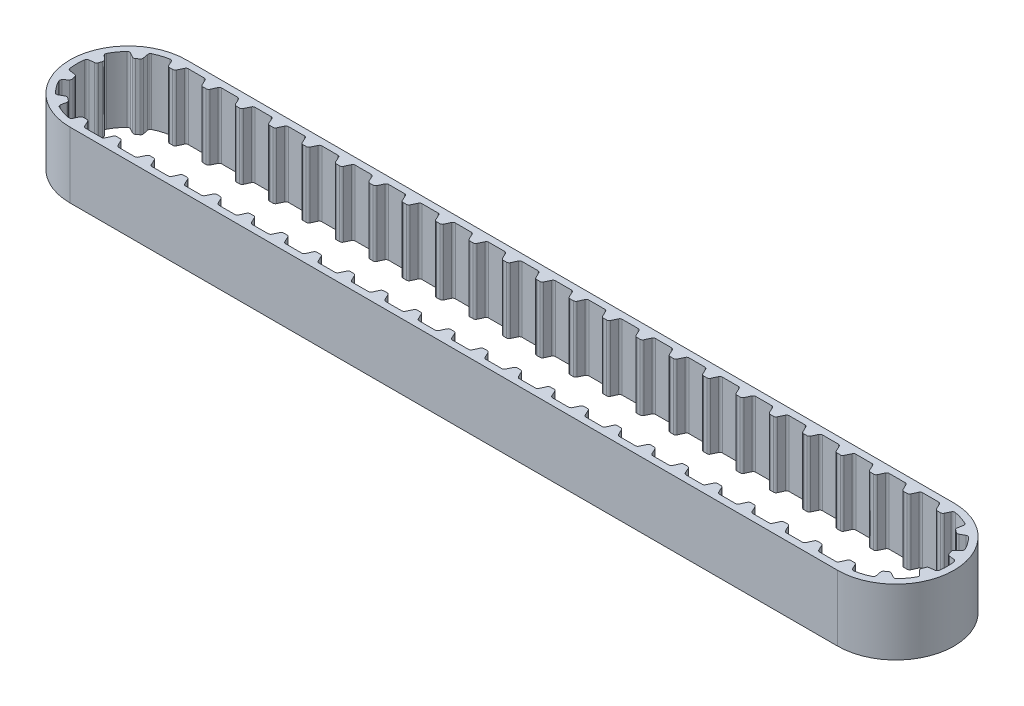
from build123d import *

# Parameters (mm, degrees)
BOSS_EXTRUDE1_DEPTH   = 10
BOSS_EXTRUDE2_DEPTH   = 10
CIRPATTERN1_COUNT     = 6
CIRPATTERN1_ANGLE     = 180.0000000000004
LPATTERN3_COUNT       = 23
LPATTERN3_PITCH       = 5.08
MIRROR1_COPY_1_DEPTH  = 10
MIRROR1_COPY_2_DEPTH  = 10
MIRROR1_COPY_3_DEPTH  = 10
MIRROR1_COPY_4_DEPTH  = 10
MIRROR1_COPY_5_DEPTH  = 10
MIRROR2_COPY_1_DEPTH  = 10
MIRROR2_COPY_2_DEPTH  = 10
MIRROR2_COPY_3_DEPTH  = 10
MIRROR2_COPY_4_DEPTH  = 10
MIRROR2_COPY_5_DEPTH  = 10
MIRROR2_COPY_6_DEPTH  = 10
MIRROR2_COPY_7_DEPTH  = 10
MIRROR2_COPY_8_DEPTH  = 10
MIRROR2_COPY_9_DEPTH  = 10
MIRROR2_COPY_10_DEPTH = 10
MIRROR2_COPY_11_DEPTH = 10
MIRROR2_COPY_12_DEPTH = 10
MIRROR2_COPY_13_DEPTH = 10
MIRROR2_COPY_14_DEPTH = 10
MIRROR2_COPY_15_DEPTH = 10
MIRROR2_COPY_16_DEPTH = 10
MIRROR2_COPY_17_DEPTH = 10
MIRROR2_COPY_18_DEPTH = 10
MIRROR2_COPY_19_DEPTH = 10
MIRROR2_COPY_20_DEPTH = 10
MIRROR2_COPY_21_DEPTH = 10
MIRROR2_COPY_22_DEPTH = 10
FILLET1_R             = 0.38


with BuildPart() as part:
    # Sketch1 → Boss-Extrude1 (new body)
    with BuildSketch(Plane(origin=(0, 0, 0), x_dir=(1, 0, 0), z_dir=(0, 1, 0))):
        with BuildLine():
            Line((0, 8.86), (116.84, 8.860000000000001))
            ThreePointArc((116.84, 8.860000000000001), (125.7, 0), (116.84, -8.860000000000001))
            Line((116.84, -8.860000000000001), (0, -8.86))
            ThreePointArc((0, -8.86), (-8.86, 1.09e-15), (0, 8.86))
        make_face()
        with BuildLine():
            Line((0, 7.829999999999998), (116.84, 7.83))
            ThreePointArc((116.84, 7.83), (124.67, 0), (116.84, -7.83))
            Line((116.84, -7.83), (0, -7.829999999999998))
            ThreePointArc((0, -7.829999999999998), (-7.829999999999998, 9.6e-16), (0, 7.829999999999998))
        make_face(mode=Mode.SUBTRACT)
    extrude(amount=BOSS_EXTRUDE1_DEPTH)

    # Sketch2 → Boss-Extrude2 (add)
    with BuildSketch(Plane(origin=(0, 10, 0), x_dir=(1, 0, 0), z_dir=(0, 1, 0))):
        with BuildLine():
            Line((-1.168761708860144, 8), (-0.4887772043281938, 6.541768524191946))
            ThreePointArc((-0.4887772043281938, 6.541768524191946), (-0.00621124619988731, 6.56), (0.4763883711050418, 6.542682378004853))
            Line((0.4763883711050418, 6.542682378004853), (1.1559467386055982, 8))
            Line((1.1559467386055982, 8), (-1.168761708860144, 8))
        make_face()
    boss_extrude2 = extrude(amount=-BOSS_EXTRUDE2_DEPTH)

    # CirPattern1: Boss-Extrude2 ×6 about axis
    cirpattern1_axis = Axis((4e-17, 0, 2.3e-16), (0, 1, 0))
    for i in range(1, CIRPATTERN1_COUNT):
        add(boss_extrude2.rotate(cirpattern1_axis, i * CIRPATTERN1_ANGLE / (CIRPATTERN1_COUNT - 1)))

    # LPattern3: Boss-Extrude2 ×23
    with Locations(*[(i * LPATTERN3_PITCH, 0, 0) for i in range(1, LPATTERN3_COUNT)]):
        add(boss_extrude2)

    # Mirror1: Boss-Extrude2 across plane
    add(boss_extrude2.mirror(Plane(origin=(58.42, 0, 0), x_dir=(0, 0, 1), z_dir=(1, 0, 0))))

    # Mirror1 copy 1 sketch → Mirror1 copy 1 (add)
    with BuildSketch(Plane(origin=(116.84, 10, 7e-17), x_dir=(-0.8090169943749467, 0, -0.5877852522924741), z_dir=(0, 1, 0))):
        with BuildLine():
            Line((-1.168761708860144, -8), (-0.4887772043281938, -6.541768524191946))
            ThreePointArc((-0.4887772043281938, -6.541768524191946), (-0.00621124619988731, -6.56), (0.4763883711050418, -6.542682378004853))
            Line((0.4763883711050418, -6.542682378004853), (1.1559467386055982, -8))
            Line((1.1559467386055982, -8), (-1.168761708860144, -8))
        make_face()
    extrude(amount=-MIRROR1_COPY_1_DEPTH)

    # Mirror1 copy 2 sketch → Mirror1 copy 2 (add)
    with BuildSketch(Plane(origin=(116.84, 10, 2e-16), x_dir=(-0.30901699437494495, 0, -0.9510565162951544), z_dir=(0, 1, 0))):
        with BuildLine():
            Line((-1.168761708860144, -8), (-0.4887772043281938, -6.541768524191946))
            ThreePointArc((-0.4887772043281938, -6.541768524191946), (-0.00621124619988731, -6.56), (0.4763883711050418, -6.542682378004853))
            Line((0.4763883711050418, -6.542682378004853), (1.1559467386055982, -8))
            Line((1.1559467386055982, -8), (-1.168761708860144, -8))
        make_face()
    extrude(amount=-MIRROR1_COPY_2_DEPTH)

    # Mirror1 copy 3 sketch → Mirror1 copy 3 (add)
    with BuildSketch(Plane(origin=(116.84, 10, 3.4e-16), x_dir=(0.30901699437495117, 0, -0.9510565162951523), z_dir=(0, 1, 0))):
        with BuildLine():
            Line((-1.168761708860144, -8), (-0.4887772043281938, -6.541768524191946))
            ThreePointArc((-0.4887772043281938, -6.541768524191946), (-0.00621124619988731, -6.56), (0.4763883711050418, -6.542682378004853))
            Line((0.4763883711050418, -6.542682378004853), (1.1559467386055982, -8))
            Line((1.1559467386055982, -8), (-1.168761708860144, -8))
        make_face()
    extrude(amount=-MIRROR1_COPY_3_DEPTH)

    # Mirror1 copy 4 sketch → Mirror1 copy 4 (add)
    with BuildSketch(Plane(origin=(116.84, 10, 4.4e-16), x_dir=(0.8090169943749504, 0, -0.5877852522924689), z_dir=(0, 1, 0))):
        with BuildLine():
            Line((-1.168761708860144, -8), (-0.4887772043281938, -6.541768524191946))
            ThreePointArc((-0.4887772043281938, -6.541768524191946), (-0.00621124619988731, -6.56), (0.4763883711050418, -6.542682378004853))
            Line((0.4763883711050418, -6.542682378004853), (1.1559467386055982, -8))
            Line((1.1559467386055982, -8), (-1.168761708860144, -8))
        make_face()
    extrude(amount=-MIRROR1_COPY_4_DEPTH)

    # Mirror1 copy 5 sketch → Mirror1 copy 5 (add)
    with BuildSketch(Plane(origin=(116.84, 10, 4.6e-16), x_dir=(1, 0, 6.98e-15), z_dir=(0, 1, 0))):
        with BuildLine():
            Line((-1.168761708860144, -8), (-0.4887772043281938, -6.541768524191946))
            ThreePointArc((-0.4887772043281938, -6.541768524191946), (-0.00621124619988731, -6.56), (0.4763883711050418, -6.542682378004853))
            Line((0.4763883711050418, -6.542682378004853), (1.1559467386055982, -8))
            Line((1.1559467386055982, -8), (-1.168761708860144, -8))
        make_face()
    extrude(amount=-MIRROR1_COPY_5_DEPTH)

    # Mirror2: Boss-Extrude2 across plane
    add(boss_extrude2.mirror(Plane.XY))

    # Mirror2 copy 1 sketch → Mirror2 copy 1 (add)
    with BuildSketch(Plane(origin=(5.08, 10, -6e-17), x_dir=(1, 0, 0), z_dir=(0, 1, 0))):
        with BuildLine():
            Line((-1.168761708860144, -8), (-0.4887772043281938, -6.541768524191946))
            ThreePointArc((-0.4887772043281938, -6.541768524191946), (-0.00621124619988731, -6.56), (0.4763883711050418, -6.542682378004853))
            Line((0.4763883711050418, -6.542682378004853), (1.1559467386055982, -8))
            Line((1.1559467386055982, -8), (-1.168761708860144, -8))
        make_face()
    extrude(amount=-MIRROR2_COPY_1_DEPTH)

    # Mirror2 copy 2 sketch → Mirror2 copy 2 (add)
    with BuildSketch(Plane(origin=(10.16, 10, -1.3e-16), x_dir=(1, 0, 0), z_dir=(0, 1, 0))):
        with BuildLine():
            Line((-1.168761708860144, -8), (-0.4887772043281938, -6.541768524191946))
            ThreePointArc((-0.4887772043281938, -6.541768524191946), (-0.00621124619988731, -6.56), (0.4763883711050418, -6.542682378004853))
            Line((0.4763883711050418, -6.542682378004853), (1.1559467386055982, -8))
            Line((1.1559467386055982, -8), (-1.168761708860144, -8))
        make_face()
    extrude(amount=-MIRROR2_COPY_2_DEPTH)

    # Mirror2 copy 3 sketch → Mirror2 copy 3 (add)
    with BuildSketch(Plane(origin=(15.24, 10, -1.9e-16), x_dir=(1, 0, 0), z_dir=(0, 1, 0))):
        with BuildLine():
            Line((-1.168761708860144, -8), (-0.4887772043281938, -6.541768524191946))
            ThreePointArc((-0.4887772043281938, -6.541768524191946), (-0.00621124619988731, -6.56), (0.4763883711050418, -6.542682378004853))
            Line((0.4763883711050418, -6.542682378004853), (1.1559467386055982, -8))
            Line((1.1559467386055982, -8), (-1.168761708860144, -8))
        make_face()
    extrude(amount=-MIRROR2_COPY_3_DEPTH)

    # Mirror2 copy 4 sketch → Mirror2 copy 4 (add)
    with BuildSketch(Plane(origin=(20.32, 10, -2.6e-16), x_dir=(1, 0, 0), z_dir=(0, 1, 0))):
        with BuildLine():
            Line((-1.168761708860144, -8), (-0.4887772043281938, -6.541768524191946))
            ThreePointArc((-0.4887772043281938, -6.541768524191946), (-0.00621124619988731, -6.56), (0.4763883711050418, -6.542682378004853))
            Line((0.4763883711050418, -6.542682378004853), (1.1559467386055982, -8))
            Line((1.1559467386055982, -8), (-1.168761708860144, -8))
        make_face()
    extrude(amount=-MIRROR2_COPY_4_DEPTH)

    # Mirror2 copy 5 sketch → Mirror2 copy 5 (add)
    with BuildSketch(Plane(origin=(25.4, 10, -3.2e-16), x_dir=(1, 0, 0), z_dir=(0, 1, 0))):
        with BuildLine():
            Line((-1.168761708860144, -8), (-0.4887772043281938, -6.541768524191946))
            ThreePointArc((-0.4887772043281938, -6.541768524191946), (-0.00621124619988731, -6.56), (0.4763883711050418, -6.542682378004853))
            Line((0.4763883711050418, -6.542682378004853), (1.1559467386055982, -8))
            Line((1.1559467386055982, -8), (-1.168761708860144, -8))
        make_face()
    extrude(amount=-MIRROR2_COPY_5_DEPTH)

    # Mirror2 copy 6 sketch → Mirror2 copy 6 (add)
    with BuildSketch(Plane(origin=(30.48, 10, -3.9e-16), x_dir=(1, 0, 0), z_dir=(0, 1, 0))):
        with BuildLine():
            Line((-1.168761708860144, -8), (-0.4887772043281938, -6.541768524191946))
            ThreePointArc((-0.4887772043281938, -6.541768524191946), (-0.00621124619988731, -6.56), (0.4763883711050418, -6.542682378004853))
            Line((0.4763883711050418, -6.542682378004853), (1.1559467386055982, -8))
            Line((1.1559467386055982, -8), (-1.168761708860144, -8))
        make_face()
    extrude(amount=-MIRROR2_COPY_6_DEPTH)

    # Mirror2 copy 7 sketch → Mirror2 copy 7 (add)
    with BuildSketch(Plane(origin=(35.56, 10, -4.5e-16), x_dir=(1, 0, 0), z_dir=(0, 1, 0))):
        with BuildLine():
            Line((-1.168761708860144, -8), (-0.4887772043281938, -6.541768524191946))
            ThreePointArc((-0.4887772043281938, -6.541768524191946), (-0.00621124619988731, -6.56), (0.4763883711050418, -6.542682378004853))
            Line((0.4763883711050418, -6.542682378004853), (1.1559467386055982, -8))
            Line((1.1559467386055982, -8), (-1.168761708860144, -8))
        make_face()
    extrude(amount=-MIRROR2_COPY_7_DEPTH)

    # Mirror2 copy 8 sketch → Mirror2 copy 8 (add)
    with BuildSketch(Plane(origin=(40.64, 10, -5.2e-16), x_dir=(1, 0, 0), z_dir=(0, 1, 0))):
        with BuildLine():
            Line((-1.168761708860144, -8), (-0.4887772043281938, -6.541768524191946))
            ThreePointArc((-0.4887772043281938, -6.541768524191946), (-0.00621124619988731, -6.56), (0.4763883711050418, -6.542682378004853))
            Line((0.4763883711050418, -6.542682378004853), (1.1559467386055982, -8))
            Line((1.1559467386055982, -8), (-1.168761708860144, -8))
        make_face()
    extrude(amount=-MIRROR2_COPY_8_DEPTH)

    # Mirror2 copy 9 sketch → Mirror2 copy 9 (add)
    with BuildSketch(Plane(origin=(45.72, 10, -5.8e-16), x_dir=(1, 0, 0), z_dir=(0, 1, 0))):
        with BuildLine():
            Line((-1.168761708860144, -8), (-0.4887772043281938, -6.541768524191946))
            ThreePointArc((-0.4887772043281938, -6.541768524191946), (-0.00621124619988731, -6.56), (0.4763883711050418, -6.542682378004853))
            Line((0.4763883711050418, -6.542682378004853), (1.1559467386055982, -8))
            Line((1.1559467386055982, -8), (-1.168761708860144, -8))
        make_face()
    extrude(amount=-MIRROR2_COPY_9_DEPTH)

    # Mirror2 copy 10 sketch → Mirror2 copy 10 (add)
    with BuildSketch(Plane(origin=(50.8, 10, -6.5e-16), x_dir=(1, 0, 0), z_dir=(0, 1, 0))):
        with BuildLine():
            Line((-1.168761708860144, -8), (-0.4887772043281938, -6.541768524191946))
            ThreePointArc((-0.4887772043281938, -6.541768524191946), (-0.00621124619988731, -6.56), (0.4763883711050418, -6.542682378004853))
            Line((0.4763883711050418, -6.542682378004853), (1.1559467386055982, -8))
            Line((1.1559467386055982, -8), (-1.168761708860144, -8))
        make_face()
    extrude(amount=-MIRROR2_COPY_10_DEPTH)

    # Mirror2 copy 11 sketch → Mirror2 copy 11 (add)
    with BuildSketch(Plane(origin=(55.88, 10, -7.1e-16), x_dir=(1, 0, 0), z_dir=(0, 1, 0))):
        with BuildLine():
            Line((-1.168761708860144, -8), (-0.4887772043281938, -6.541768524191946))
            ThreePointArc((-0.4887772043281938, -6.541768524191946), (-0.00621124619988731, -6.56), (0.4763883711050418, -6.542682378004853))
            Line((0.4763883711050418, -6.542682378004853), (1.1559467386055982, -8))
            Line((1.1559467386055982, -8), (-1.168761708860144, -8))
        make_face()
    extrude(amount=-MIRROR2_COPY_11_DEPTH)

    # Mirror2 copy 12 sketch → Mirror2 copy 12 (add)
    with BuildSketch(Plane(origin=(60.96, 10, -7.7e-16), x_dir=(1, 0, 0), z_dir=(0, 1, 0))):
        with BuildLine():
            Line((-1.168761708860144, -8), (-0.4887772043281938, -6.541768524191946))
            ThreePointArc((-0.4887772043281938, -6.541768524191946), (-0.00621124619988731, -6.56), (0.4763883711050418, -6.542682378004853))
            Line((0.4763883711050418, -6.542682378004853), (1.1559467386055982, -8))
            Line((1.1559467386055982, -8), (-1.168761708860144, -8))
        make_face()
    extrude(amount=-MIRROR2_COPY_12_DEPTH)

    # Mirror2 copy 13 sketch → Mirror2 copy 13 (add)
    with BuildSketch(Plane(origin=(66.04, 10, -8.4e-16), x_dir=(1, 0, 0), z_dir=(0, 1, 0))):
        with BuildLine():
            Line((-1.168761708860144, -8), (-0.4887772043281938, -6.541768524191946))
            ThreePointArc((-0.4887772043281938, -6.541768524191946), (-0.00621124619988731, -6.56), (0.4763883711050418, -6.542682378004853))
            Line((0.4763883711050418, -6.542682378004853), (1.1559467386055982, -8))
            Line((1.1559467386055982, -8), (-1.168761708860144, -8))
        make_face()
    extrude(amount=-MIRROR2_COPY_13_DEPTH)

    # Mirror2 copy 14 sketch → Mirror2 copy 14 (add)
    with BuildSketch(Plane(origin=(71.12, 10, -9e-16), x_dir=(1, 0, 0), z_dir=(0, 1, 0))):
        with BuildLine():
            Line((-1.168761708860144, -8), (-0.4887772043281938, -6.541768524191946))
            ThreePointArc((-0.4887772043281938, -6.541768524191946), (-0.00621124619988731, -6.56), (0.4763883711050418, -6.542682378004853))
            Line((0.4763883711050418, -6.542682378004853), (1.1559467386055982, -8))
            Line((1.1559467386055982, -8), (-1.168761708860144, -8))
        make_face()
    extrude(amount=-MIRROR2_COPY_14_DEPTH)

    # Mirror2 copy 15 sketch → Mirror2 copy 15 (add)
    with BuildSketch(Plane(origin=(76.2, 10, -9.7e-16), x_dir=(1, 0, 0), z_dir=(0, 1, 0))):
        with BuildLine():
            Line((-1.168761708860144, -8), (-0.4887772043281938, -6.541768524191946))
            ThreePointArc((-0.4887772043281938, -6.541768524191946), (-0.00621124619988731, -6.56), (0.4763883711050418, -6.542682378004853))
            Line((0.4763883711050418, -6.542682378004853), (1.1559467386055982, -8))
            Line((1.1559467386055982, -8), (-1.168761708860144, -8))
        make_face()
    extrude(amount=-MIRROR2_COPY_15_DEPTH)

    # Mirror2 copy 16 sketch → Mirror2 copy 16 (add)
    with BuildSketch(Plane(origin=(81.28, 10, -1.03e-15), x_dir=(1, 0, 0), z_dir=(0, 1, 0))):
        with BuildLine():
            Line((-1.168761708860144, -8), (-0.4887772043281938, -6.541768524191946))
            ThreePointArc((-0.4887772043281938, -6.541768524191946), (-0.00621124619988731, -6.56), (0.4763883711050418, -6.542682378004853))
            Line((0.4763883711050418, -6.542682378004853), (1.1559467386055982, -8))
            Line((1.1559467386055982, -8), (-1.168761708860144, -8))
        make_face()
    extrude(amount=-MIRROR2_COPY_16_DEPTH)

    # Mirror2 copy 17 sketch → Mirror2 copy 17 (add)
    with BuildSketch(Plane(origin=(86.36, 10, -1.1e-15), x_dir=(1, 0, 0), z_dir=(0, 1, 0))):
        with BuildLine():
            Line((-1.168761708860144, -8), (-0.4887772043281938, -6.541768524191946))
            ThreePointArc((-0.4887772043281938, -6.541768524191946), (-0.00621124619988731, -6.56), (0.4763883711050418, -6.542682378004853))
            Line((0.4763883711050418, -6.542682378004853), (1.1559467386055982, -8))
            Line((1.1559467386055982, -8), (-1.168761708860144, -8))
        make_face()
    extrude(amount=-MIRROR2_COPY_17_DEPTH)

    # Mirror2 copy 18 sketch → Mirror2 copy 18 (add)
    with BuildSketch(Plane(origin=(91.44, 10, -1.16e-15), x_dir=(1, 0, 0), z_dir=(0, 1, 0))):
        with BuildLine():
            Line((-1.168761708860144, -8), (-0.4887772043281938, -6.541768524191946))
            ThreePointArc((-0.4887772043281938, -6.541768524191946), (-0.00621124619988731, -6.56), (0.4763883711050418, -6.542682378004853))
            Line((0.4763883711050418, -6.542682378004853), (1.1559467386055982, -8))
            Line((1.1559467386055982, -8), (-1.168761708860144, -8))
        make_face()
    extrude(amount=-MIRROR2_COPY_18_DEPTH)

    # Mirror2 copy 19 sketch → Mirror2 copy 19 (add)
    with BuildSketch(Plane(origin=(96.52, 10, -1.23e-15), x_dir=(1, 0, 0), z_dir=(0, 1, 0))):
        with BuildLine():
            Line((-1.168761708860144, -8), (-0.4887772043281938, -6.541768524191946))
            ThreePointArc((-0.4887772043281938, -6.541768524191946), (-0.00621124619988731, -6.56), (0.4763883711050418, -6.542682378004853))
            Line((0.4763883711050418, -6.542682378004853), (1.1559467386055982, -8))
            Line((1.1559467386055982, -8), (-1.168761708860144, -8))
        make_face()
    extrude(amount=-MIRROR2_COPY_19_DEPTH)

    # Mirror2 copy 20 sketch → Mirror2 copy 20 (add)
    with BuildSketch(Plane(origin=(101.6, 10, -1.29e-15), x_dir=(1, 0, 0), z_dir=(0, 1, 0))):
        with BuildLine():
            Line((-1.168761708860144, -8), (-0.4887772043281938, -6.541768524191946))
            ThreePointArc((-0.4887772043281938, -6.541768524191946), (-0.00621124619988731, -6.56), (0.4763883711050418, -6.542682378004853))
            Line((0.4763883711050418, -6.542682378004853), (1.1559467386055982, -8))
            Line((1.1559467386055982, -8), (-1.168761708860144, -8))
        make_face()
    extrude(amount=-MIRROR2_COPY_20_DEPTH)

    # Mirror2 copy 21 sketch → Mirror2 copy 21 (add)
    with BuildSketch(Plane(origin=(106.68, 10, -1.35e-15), x_dir=(1, 0, 0), z_dir=(0, 1, 0))):
        with BuildLine():
            Line((-1.168761708860144, -8), (-0.4887772043281938, -6.541768524191946))
            ThreePointArc((-0.4887772043281938, -6.541768524191946), (-0.00621124619988731, -6.56), (0.4763883711050418, -6.542682378004853))
            Line((0.4763883711050418, -6.542682378004853), (1.1559467386055982, -8))
            Line((1.1559467386055982, -8), (-1.168761708860144, -8))
        make_face()
    extrude(amount=-MIRROR2_COPY_21_DEPTH)

    # Mirror2 copy 22 sketch → Mirror2 copy 22 (add)
    with BuildSketch(Plane(origin=(111.76, 10, -1.42e-15), x_dir=(1, 0, 0), z_dir=(0, 1, 0))):
        with BuildLine():
            Line((-1.168761708860144, -8), (-0.4887772043281938, -6.541768524191946))
            ThreePointArc((-0.4887772043281938, -6.541768524191946), (-0.00621124619988731, -6.56), (0.4763883711050418, -6.542682378004853))
            Line((0.4763883711050418, -6.542682378004853), (1.1559467386055982, -8))
            Line((1.1559467386055982, -8), (-1.168761708860144, -8))
        make_face()
    extrude(amount=-MIRROR2_COPY_22_DEPTH)

    # Fillet1
    fillet1_edges = [part.edges().sort_by_distance(p)[0] for p in [
        (-6.070551120426782, 5, 2.4863723924353116),
        (41.716674436719245, 5, 7.829999999999999),
        (39.55051059302621, 5, 7.829999999999999),
        (40.151222795671806, 5, 6.541768524191945),
        (41.116388371105046, 5, 6.542682378004852),
        (-7.702908480901908, 5, 1.4050270228182267),
        (46.796674436719236, 5, 7.829999999999999),
        (44.6305105930262, 5, 7.829999999999999),
        (45.231222795671805, 5, 6.541768524191945),
        (46.196388371105044, 5, 6.542682378004852),
        (51.87667443671924, 5, 7.829999999999999),
        (49.7105105930262, 5, 7.829999999999999),
        (50.3112227956718, 5, 6.541768524191945),
        (51.27638837110504, 5, 6.542682378004852),
        (56.95667443671925, 5, 7.829999999999999),
        (54.790510593026205, 5, 7.829999999999999),
        (55.39122279567181, 5, 6.541768524191945),
        (56.35638837110504, 5, 6.542682378004852),
        (62.03667443671924, 5, 7.829999999999999),
        (59.870510593026204, 5, 7.829999999999999),
        (60.47122279567181, 5, 6.541768524191945),
        (61.43638837110504, 5, 6.542682378004852),
        (67.11667443671925, 5, 7.829999999999999),
        (64.95051059302622, 5, 7.829999999999999),
        (65.55122279567182, 5, 6.541768524191945),
        (66.51638837110505, 5, 6.542682378004852),
        (72.19667443671926, 5, 7.829999999999999),
        (70.03051059302621, 5, 7.829999999999999),
        (70.63122279567182, 5, 6.541768524191945),
        (71.59638837110505, 5, 6.542682378004852),
        (77.27667443671925, 5, 7.829999999999999),
        (75.1105105930262, 5, 7.829999999999999),
        (75.71122279567182, 5, 6.541768524191945),
        (76.67638837110505, 5, 6.542682378004852),
        (82.35667443671926, 5, 7.829999999999999),
        (80.1905105930262, 5, 7.829999999999999),
        (80.79122279567181, 5, 6.541768524191945),
        (81.75638837110505, 5, 6.542682378004852),
        (-4.231098500371653, 5, 5.013127173704265),
        (-3.705878746643041, 5, 6.897489595148324),
        (87.43667443671924, 5, 7.829999999999999),
        (85.27051059302619, 5, 7.829999999999999),
        (-3.4497259976665084, 5, 5.579697941699279),
        (85.87122279567181, 5, 6.541768524191945),
        (86.83638837110504, 5, 6.542682378004852),
        (-5.405929704079593, 5, 5.664346743848748),
        (92.51667443671926, 5, 7.83),
        (90.3505105930262, 5, 7.83),
        (90.95122279567181, 5, 6.541768524191945),
        (91.91638837110504, 5, 6.542682378004852),
        (97.59667443671924, 5, 7.83),
        (95.43051059302618, 5, 7.83),
        (96.03122279567181, 5, 6.541768524191945),
        (96.99638837110504, 5, 6.542682378004852),
        (102.67667443671925, 5, 7.83),
        (100.5105105930262, 5, 7.83),
        (101.11122279567181, 5, 6.541768524191945),
        (102.07638837110504, 5, 6.542682378004852),
        (107.75667443671927, 5, 7.83),
        (105.59051059302621, 5, 7.83),
        (106.19122279567182, 5, 6.541768524191944),
        (107.15638837110505, 5, 6.5426823780048515),
        (112.83667443671925, 5, 7.83),
        (110.6705105930262, 5, 7.83),
        (111.27122279567182, 5, 6.541768524191944),
        (112.23638837110505, 5, 6.5426823780048515),
        (1.089489406973846, 5, 7.829999999999998),
        (0.4887772043282396, 5, 6.541768524191943),
        (6.156674436719248, 5, -7.829999999999998),
        (3.9905105930262055, 5, -7.829999999999998),
        (5.556388371105042, 5, -6.542682378004853),
        (4.591222795671806, 5, -6.541768524191946),
        (11.236674436719248, 5, -7.829999999999998),
        (9.070510593026206, 5, -7.829999999999998),
        (10.636388371105042, 5, -6.542682378004853),
        (9.671222795671806, 5, -6.541768524191946),
        (16.31667443671925, 5, -7.829999999999998),
        (14.150510593026205, 5, -7.829999999999998),
        (15.716388371105042, 5, -6.542682378004853),
        (14.751222795671806, 5, -6.541768524191946),
        (21.396674436719245, 5, -7.829999999999998),
        (19.230510593026203, 5, -7.829999999999998),
        (20.796388371105042, 5, -6.542682378004853),
        (19.831222795671806, 5, -6.541768524191946),
        (26.476674436719247, 5, -7.829999999999998),
        (24.3105105930262, 5, -7.829999999999998),
        (25.87638837110504, 5, -6.542682378004853),
        (24.911222795671804, 5, -6.541768524191946),
        (31.55667443671925, 5, -7.829999999999999),
        (29.390510593026203, 5, -7.829999999999999),
        (30.956388371105042, 5, -6.542682378004853),
        (29.991222795671806, 5, -6.541768524191946),
        (1.076674436719249, 5, -7.829999999999998),
        (36.636674436719254, 5, -7.829999999999999),
        (34.470510593026205, 5, -7.829999999999999),
        (36.03638837110505, 5, -6.542682378004852),
        (35.07122279567181, 5, -6.541768524191945),
        (-1.0561237767417748, 5, -7.758447175060267),
        (41.716674436719245, 5, -7.829999999999999),
        (39.5505105930262, 5, -7.829999999999999),
        (41.116388371105046, 5, -6.542682378004852),
        (40.151222795671806, 5, -6.541768524191945),
        (46.79667443671924, 5, -7.829999999999999),
        (44.6305105930262, 5, -7.829999999999999),
        (46.196388371105044, 5, -6.542682378004852),
        (45.231222795671805, 5, -6.541768524191945),
        (0.47638837110504184, 5, -6.542682378004853),
        (-0.4887772043281938, 5, -6.541768524191946),
        (51.87667443671924, 5, -7.829999999999999),
        (49.7105105930262, 5, -7.829999999999999),
        (51.27638837110504, 5, -6.542682378004852),
        (50.3112227956718, 5, -6.541768524191945),
        (56.95667443671925, 5, -7.829999999999999),
        (54.790510593026205, 5, -7.829999999999999),
        (56.35638837110504, 5, -6.542682378004852),
        (55.39122279567181, 5, -6.541768524191945),
        (62.036674436719245, 5, -7.829999999999999),
        (59.87051059302621, 5, -7.829999999999999),
        (61.43638837110504, 5, -6.542682378004852),
        (60.47122279567181, 5, -6.541768524191945),
        (67.11667443671926, 5, -7.829999999999999),
        (64.95051059302621, 5, -7.829999999999999),
        (66.51638837110505, 5, -6.542682378004852),
        (65.55122279567182, 5, -6.541768524191945),
        (72.19667443671926, 5, -7.829999999999999),
        (70.03051059302621, 5, -7.829999999999999),
        (71.59638837110505, 5, -6.542682378004852),
        (70.63122279567182, 5, -6.541768524191945),
        (77.27667443671925, 5, -7.829999999999999),
        (75.1105105930262, 5, -7.829999999999999),
        (76.67638837110505, 5, -6.542682378004852),
        (75.71122279567182, 5, -6.541768524191945),
        (82.35667443671926, 5, -7.829999999999999),
        (80.1905105930262, 5, -7.829999999999999),
        (81.75638837110505, 5, -6.542682378004852),
        (80.79122279567181, 5, -6.541768524191945),
        (-3.716589732335633, 5, -6.891724077580103),
        (87.43667443671926, 5, -7.829999999999999),
        (85.27051059302619, 5, -7.829999999999999),
        (-5.414722913738181, 5, -5.655941634019808),
        (86.83638837110504, 5, -6.542682378004852),
        (85.87122279567181, 5, -6.541768524191945),
        (92.51667443671926, 5, -7.83),
        (90.3505105930262, 5, -7.83),
        (91.91638837110504, 5, -6.542682378004852),
        (90.95122279567181, 5, -6.541768524191945),
        (97.59667443671924, 5, -7.83),
        (95.43051059302618, 5, -7.83),
        (96.99638837110504, 5, -6.542682378004852),
        (96.03122279567181, 5, -6.541768524191945),
        (-3.46028592407853, 5, -5.573155291502593),
        (-4.240584127195714, 5, -5.005105876977542),
        (102.67667443671925, 5, -7.83),
        (100.51051059302618, 5, -7.83),
        (102.07638837110504, 5, -6.542682378004852),
        (101.11122279567181, 5, -6.541768524191945),
        (107.75667443671927, 5, -7.83),
        (105.59051059302621, 5, -7.83),
        (107.15638837110505, 5, -6.5426823780048515),
        (106.19122279567182, 5, -6.541768524191944),
        (112.83667443671925, 5, -7.83),
        (110.6705105930262, 5, -7.83),
        (112.23638837110505, 5, -6.5426823780048515),
        (111.27122279567182, 5, -6.541768524191944),
        (115.76332556328074, 5, -7.83),
        (117.89612377674179, 5, -7.758447175060271),
        (117.32877720432819, 5, -6.541768524191946),
        (116.36361162889496, 5, -6.542682378004853),
        (120.55658973233562, 5, -6.891724077580106),
        (122.25472291373818, 5, -5.655941634019804),
        (121.08058412719572, 5, -5.005105876977542),
        (120.30028592407854, 5, -5.573155291502593),
        (123.89763803024951, 5, -3.3909652658167717),
        (124.54508193734945, 5, -1.3930586271693923),
        (123.21263204562777, 5, -1.5566629020495575),
        (122.91524860705694, 5, -2.4748723082276616),
        (124.5429084809019, 5, 1.4050270228182282),
        (123.89236154699611, 5, 3.4019254269384693),
        (122.91055112042679, 5, 2.4863723924353116),
        (123.20967281224505, 5, 1.5687277789743352),
        (122.24592970407959, 5, 5.6643467438487445),
        (120.54587874664306, 5, 6.897489595148322),
        (120.28972599766651, 5, 5.579697941699278),
        (121.07109850037166, 5, 5.013127173704264),
        (115.75051059302615, 5, 7.83),
        (-6.0752486070569365, 5, -2.474872308227662),
        (117.88406952109153, 5, 7.760078532793837),
        (-7.705081937349458, 5, -1.3930586271693919),
        (116.35122279567176, 5, 6.541768524191943),
        (117.316388371105, 5, 6.542682378004858),
        (-6.372632045627773, 5, -1.556662902049558),
        (-7.057638030249501, 5, -3.3909652658167873),
        (-1.0561237767417748, 5, 7.758447175060268),
        (-0.4887772043281938, 5, 6.541768524191946),
        (6.156674436719246, 5, 7.829999999999998),
        (3.9905105930262033, 5, 7.829999999999998),
        (4.591222795671806, 5, 6.541768524191946),
        (5.556388371105042, 5, 6.542682378004853),
        (11.236674436719245, 5, 7.829999999999998),
        (9.07051059302621, 5, 7.829999999999998),
        (9.671222795671806, 5, 6.541768524191946),
        (10.636388371105042, 5, 6.542682378004853),
        (16.316674436719246, 5, 7.829999999999998),
        (14.150510593026201, 5, 7.829999999999998),
        (14.751222795671806, 5, 6.541768524191946),
        (15.716388371105042, 5, 6.542682378004853),
        (21.396674436719252, 5, 7.829999999999998),
        (19.230510593026207, 5, 7.829999999999998),
        (19.831222795671806, 5, 6.541768524191946),
        (20.796388371105042, 5, 6.542682378004853),
        (26.476674436719243, 5, 7.829999999999998),
        (24.310510593026198, 5, 7.829999999999998),
        (24.911222795671804, 5, 6.541768524191946),
        (25.87638837110504, 5, 6.542682378004853),
        (31.55667443671924, 5, 7.829999999999999),
        (29.390510593026214, 5, 7.829999999999999),
        (29.991222795671806, 5, 6.541768524191946),
        (30.956388371105042, 5, 6.542682378004853),
        (36.63667443671925, 5, 7.829999999999999),
        (34.470510593026205, 5, 7.829999999999999),
        (35.07122279567181, 5, 6.541768524191945),
        (36.03638837110505, 5, 6.542682378004852),
        (-6.369672812245038, 5, 1.5687277789743352),
        (-7.052361546996119, 5, 3.4019254269384676),
    ]]
    fillet(fillet1_edges, radius=FILLET1_R)


solid = part.part
